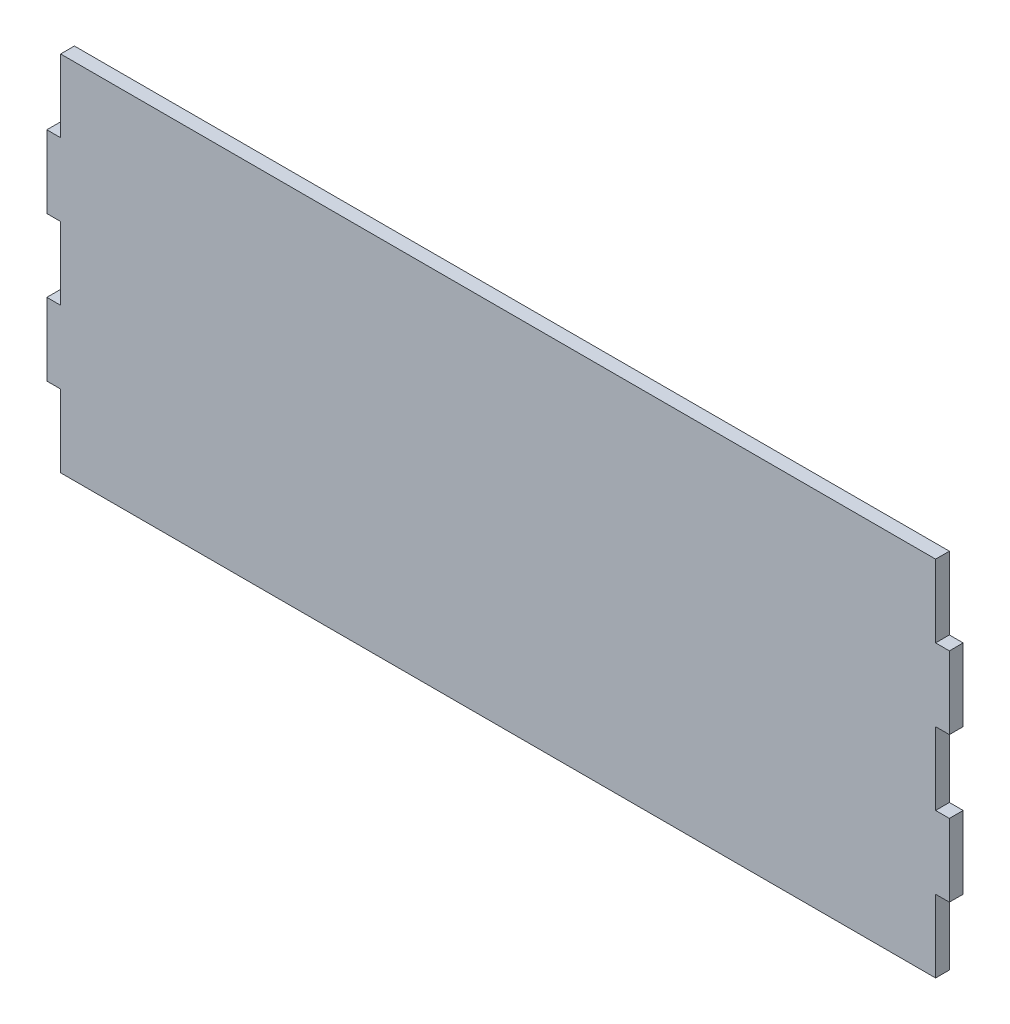
from build123d import *

# Parameters (mm, degrees)
BOSS_EXTRUDE1_DEPTH = 4.826


with BuildPart() as part:
    # Sketch1 → Boss-Extrude1 (new body)
    with BuildSketch(Plane.XY):
        Polygon((0, 76.2), (0, 101.6), (4.826, 101.6), (4.826, 127), (311.15, 127), (311.15, 101.6), (315.976, 101.6), (315.976, 76.2), (311.15, 76.2), (311.15, 50.8), (315.976, 50.8), (315.976, 25.4), (311.15, 25.4), (311.15, 0), (4.826, 0), (4.826, 25.4), (0, 25.4), (0, 50.8), (4.826, 50.8), (4.826, 76.2), align=None)
    extrude(amount=BOSS_EXTRUDE1_DEPTH)


solid = part.part
